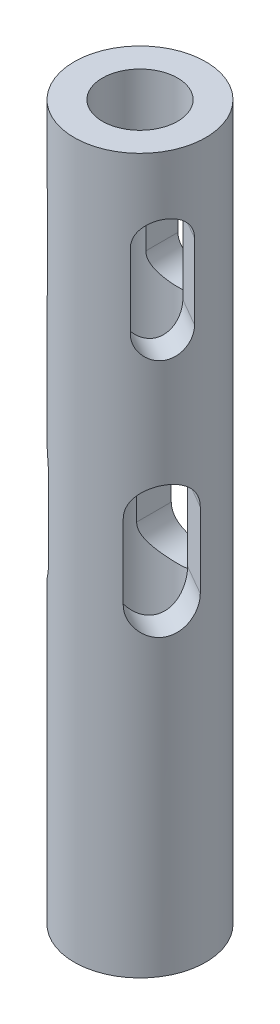
from build123d import *

# Parameters (mm, degrees)
CUT_EXTRUDE1_DEPTH = 10
CIRPATTERN1_COUNT  = 3


with BuildPart() as part:
    # Sketch1 → Revolve1 (revolve)
    with BuildSketch(Plane.XY):
        Polygon((-0.5, -38), (-0.5, 38), (-3.5, 38), (-3.5, -23.32914466), (-3.5, -38), align=None)
    revolve(axis=Axis((3.5, 38, 0), (0, -1, 0)))

    # Sketch3 → Cut-Extrude1 (cut)
    with BuildSketch(Plane.XY):
        with BuildLine():
            Line((1, 21.251316376), (1, 29.251316376))
            ThreePointArc((1, 29.251316376), (3.5, 31.751316376), (6, 29.251316376))
            Line((6, 29.251316376), (6, 21.251316376))
            ThreePointArc((6, 21.251316376), (3.5, 18.751316376), (1, 21.251316376))
        make_face()
        with BuildLine():
            Line((6.5, 4.25), (6.5, -3.75))
            ThreePointArc((6.5, -3.75), (3.5, -6.75), (0.5, -3.75))
            Line((0.5, -3.75), (0.5, 4.25))
            ThreePointArc((0.5, 4.25), (3.5, 7.25), (6.5, 4.25))
        make_face()
    cut_extrude1 = extrude(amount=-CUT_EXTRUDE1_DEPTH, mode=Mode.SUBTRACT)

    # CirPattern1: Cut-Extrude1 ×3 about axis
    cirpattern1_axis = Axis((3.5, 0, 0), (0, 1, 0))
    for i in range(1, CIRPATTERN1_COUNT):
        add(cut_extrude1.rotate(cirpattern1_axis, i * 360 / CIRPATTERN1_COUNT), mode=Mode.SUBTRACT)


solid = part.part
